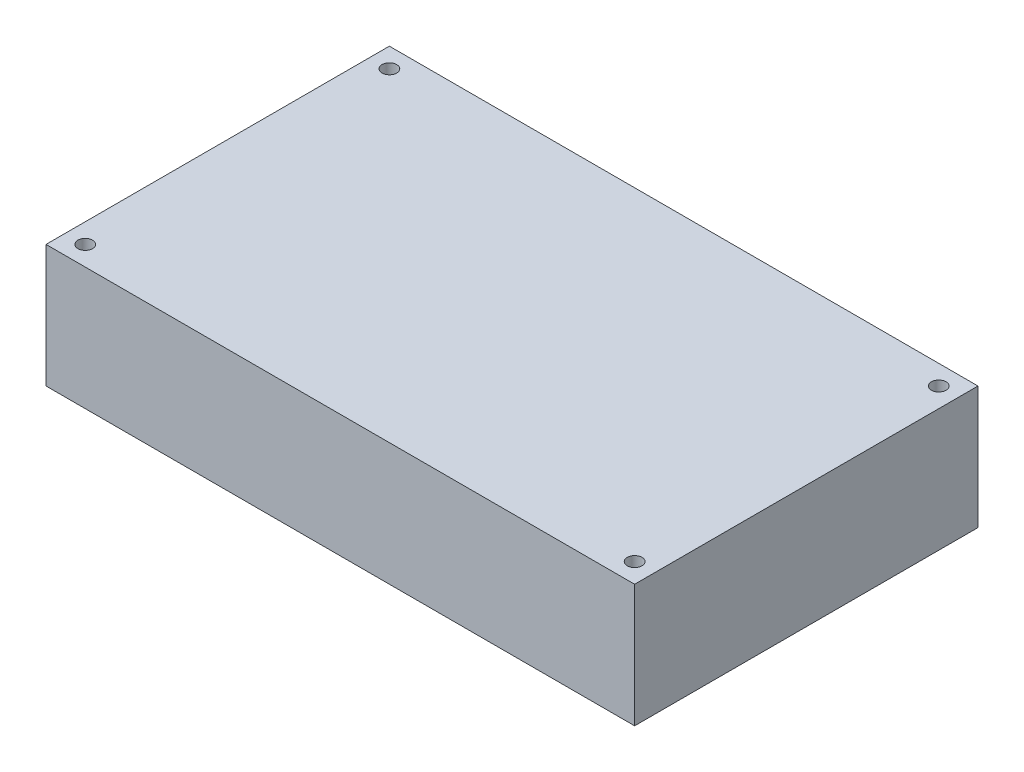
from build123d import *

# Parameters (mm, degrees)
SKETCH1_W               = 120
SKETCH1_H               = 70
BOSS_EXTRUDE1_DEPTH     = 25
SKETCH2_R               = 1.5
CUT_EXTRUDE1_DEPTH      = 1
CUT_EXTRUDE1_DEPTH_BACK = 26


with BuildPart() as part:
    # Sketch1 → Boss-Extrude1 (new body)
    with BuildSketch(Plane(origin=(0, 0, 0), x_dir=(1, 0, 0), z_dir=(0, 1, 0))):
        Rectangle(SKETCH1_W, SKETCH1_H)
    extrude(amount=BOSS_EXTRUDE1_DEPTH)

    # Sketch2 → Cut-Extrude1 (cut, two sides)
    with BuildSketch(Plane(origin=(0, 25, 0), x_dir=(1, 0, 0), z_dir=(0, 1, 0))) as cut_extrude1_sk:
        with Locations((-56, 31)):
            Circle(SKETCH2_R)
        with Locations((56, 31)):
            Circle(SKETCH2_R)
        with Locations((56, -31)):
            Circle(SKETCH2_R)
        with Locations((-56, -31)):
            Circle(SKETCH2_R)
    extrude(amount=CUT_EXTRUDE1_DEPTH, mode=Mode.SUBTRACT)
    extrude(cut_extrude1_sk.sketch, amount=-CUT_EXTRUDE1_DEPTH_BACK, mode=Mode.SUBTRACT)


solid = part.part
